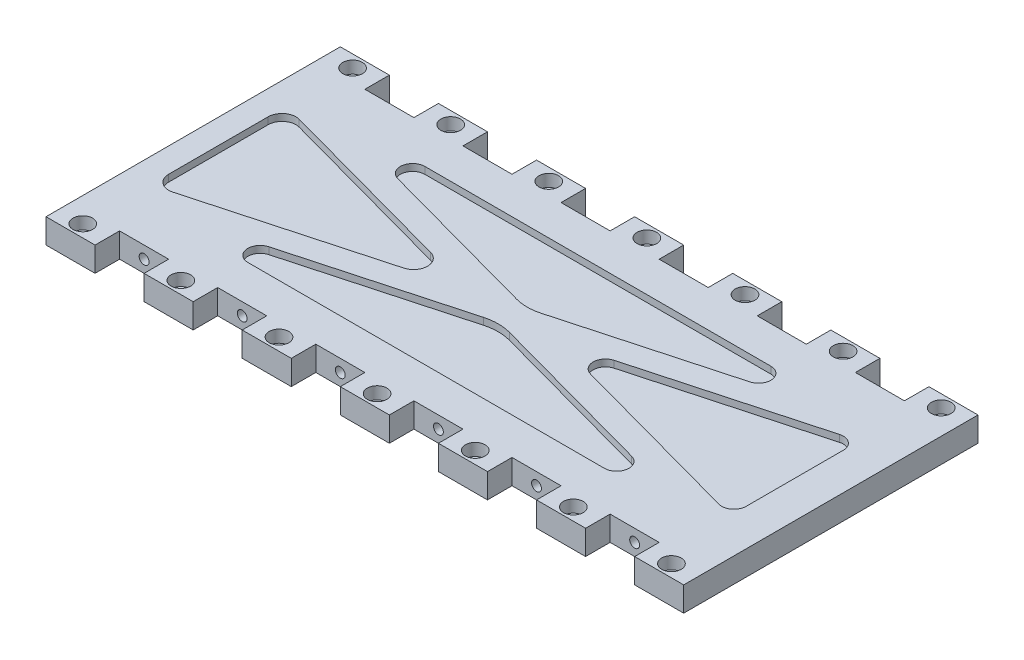
from build123d import *

# Parameters (mm, degrees)
SKETCH1_W           = 330.2
SKETCH1_H           = 127
BOSS_EXTRUDE1_DEPTH = 12.7
CUT_EXTRUDE1_DEPTH  = 3.556
SKETCH3_W           = 25.4
SKETCH3_H           = 12.7
BOSS_EXTRUDE2_DEPTH = 12.7
SKETCH4_R           = 3.2385
CUT_EXTRUDE2_DEPTH  = 25.4
SKETCH5_R           = 5.08
CUT_EXTRUDE3_DEPTH  = 6.35
SKETCH6_R           = 2.5527
CUT_EXTRUDE4_DEPTH  = 25.4


with BuildPart() as part:
    # Sketch1 → Boss-Extrude1 (new body)
    with BuildSketch(Plane(origin=(0, 0, 0), x_dir=(1, 0, 0), z_dir=(0, 1, 0))):
        Rectangle(SKETCH1_W, SKETCH1_H)
    extrude(amount=BOSS_EXTRUDE1_DEPTH)

    # Sketch2 → Cut-Extrude1 (cut)
    with BuildSketch(Plane(origin=(0, 12.7, 0), x_dir=(1, 0, 0), z_dir=(0, 1, 0))):
        with BuildLine():
            Line((-89.555550869, 44.45), (89.555550869, 44.45))
            ThreePointArc((89.555550869, 44.45), (95.848789674, 38.947139505), (91.234685107, 31.976030029))
            Line((91.234685107, 31.976030029), (6.256412404, 8.675797038))
            ThreePointArc((6.256412404, 8.675797038), (0, 7.833614774), (-6.256412404, 8.675797038))
            Line((-6.256412404, 8.675797038), (-91.234685107, 31.976030029))
            ThreePointArc((-91.234685107, 31.976030029), (-95.848789674, 38.947139505), (-89.555550869, 44.45))
        make_face()
        with BuildLine():
            Line((-152.4, 26.105568393), (-152.4, -25.353616872))
            ThreePointArc((-152.4, -25.353616872), (-149.556629033, -31.098337724), (-143.26451887, -32.321418189))
            Line((-143.26451887, -32.321418189), (-49.42612935, -6.591825556))
            ThreePointArc((-49.42612935, -6.591825556), (-44.111657731, 0.375975761), (-49.42612935, 7.343777077))
            Line((-49.42612935, 7.343777077), (-143.26451887, 33.07336971))
            ThreePointArc((-143.26451887, 33.07336971), (-149.556629033, 31.850289245), (-152.4, 26.105568393))
        make_face()
        with BuildLine():
            Line((-92.297993035, -44.45), (92.297993035, -44.45))
            ThreePointArc((92.297993035, -44.45), (98.59123184, -38.947139505), (93.977127273, -31.976030029))
            Line((93.977127273, -31.976030029), (6.716536951, -8.050007285))
            ThreePointArc((6.716536951, -8.050007285), (0, -7.145887171), (-6.716536951, -8.050007285))
            Line((-6.716536951, -8.050007285), (-93.977127273, -31.976030029))
            ThreePointArc((-93.977127273, -31.976030029), (-98.59123184, -38.947139505), (-92.297993035, -44.45))
        make_face()
        with BuildLine():
            Line((146.05, 25.51164), (146.05, -24.759688479))
            ThreePointArc((146.05, -24.759688479), (143.550973746, -29.808698402), (138.020865762, -30.88365845))
            Line((138.020865762, -30.88365845), (46.348592305, -5.747994211))
            ThreePointArc((46.348592305, -5.747994211), (41.677726543, 0.375975761), (46.348592305, 6.499945732))
            Line((46.348592305, 6.499945732), (138.020865762, 31.635609971))
            ThreePointArc((138.020865762, 31.635609971), (143.550973746, 30.560649923), (146.05, 25.51164))
        make_face()
    cut_extrude1 = extrude(amount=-CUT_EXTRUDE1_DEPTH, mode=Mode.SUBTRACT)

    # Sketch3 → Boss-Extrude2 (add)
    with BuildSketch(Plane.XZ):
        with Locations((-101.6, 69.85)):
            Rectangle(SKETCH3_W, SKETCH3_H)
        with Locations((-152.4, 69.85)):
            Rectangle(SKETCH3_W, SKETCH3_H)
        with Locations((-50.8, 69.85)):
            Rectangle(SKETCH3_W, SKETCH3_H)
        with Locations((0, 69.85)):
            Rectangle(SKETCH3_W, SKETCH3_H)
        with Locations((50.8, 69.85)):
            Rectangle(SKETCH3_W, SKETCH3_H)
        with Locations((101.6, 69.85)):
            Rectangle(SKETCH3_W, SKETCH3_H)
        with Locations((152.4, 69.85)):
            Rectangle(SKETCH3_W, SKETCH3_H)
        with Locations((-101.6, -69.85)):
            Rectangle(SKETCH3_W, SKETCH3_H)
        with Locations((-50.8, -69.85)):
            Rectangle(SKETCH3_W, SKETCH3_H)
        with Locations((0, -69.85)):
            Rectangle(SKETCH3_W, SKETCH3_H)
        with Locations((50.8, -69.85)):
            Rectangle(SKETCH3_W, SKETCH3_H)
        with Locations((101.6, -69.85)):
            Rectangle(SKETCH3_W, SKETCH3_H)
        with Locations((152.4, -69.85)):
            Rectangle(SKETCH3_W, SKETCH3_H)
        with Locations((-152.4, -69.85)):
            Rectangle(SKETCH3_W, SKETCH3_H)
    extrude(amount=-BOSS_EXTRUDE2_DEPTH)

    # Sketch4 → Cut-Extrude2 (cut)
    with BuildSketch(Plane(origin=(0, 12.7, 0), x_dir=(1, 0, 0), z_dir=(0, 1, 0))):
        with Locations((-152.4, 69.85)):
            Circle(SKETCH4_R)
        with Locations((-101.6, 69.85)):
            Circle(SKETCH4_R)
        with Locations((-50.8, 69.85)):
            Circle(SKETCH4_R)
        with Locations((0, 69.85)):
            Circle(SKETCH4_R)
        with Locations((50.8, 69.85)):
            Circle(SKETCH4_R)
        with Locations((101.6, 69.85)):
            Circle(SKETCH4_R)
        with Locations((152.4, 69.85)):
            Circle(SKETCH4_R)
        with Locations((-101.6, -69.85)):
            Circle(SKETCH4_R)
        with Locations((-50.8, -69.85)):
            Circle(SKETCH4_R)
        with Locations((0, -69.85)):
            Circle(SKETCH4_R)
        with Locations((50.8, -69.85)):
            Circle(SKETCH4_R)
        with Locations((101.6, -69.85)):
            Circle(SKETCH4_R)
        with Locations((152.4, -69.85)):
            Circle(SKETCH4_R)
        with Locations((-152.4, -69.85)):
            Circle(SKETCH4_R)
    extrude(amount=-CUT_EXTRUDE2_DEPTH, mode=Mode.SUBTRACT)

    # Sketch5 → Cut-Extrude3 (cut)
    with BuildSketch(Plane(origin=(0, 12.7, 0), x_dir=(1, 0, 0), z_dir=(0, 1, 0))):
        with Locations((-152.4, 69.85)):
            Circle(SKETCH5_R)
        with Locations((-101.6, 69.85)):
            Circle(SKETCH5_R)
        with Locations((-50.8, 69.85)):
            Circle(SKETCH5_R)
        with Locations((0, 69.85)):
            Circle(SKETCH5_R)
        with Locations((50.8, 69.85)):
            Circle(SKETCH5_R)
        with Locations((101.6, 69.85)):
            Circle(SKETCH5_R)
        with Locations((152.4, 69.85)):
            Circle(SKETCH5_R)
        with Locations((-101.6, -69.85)):
            Circle(SKETCH5_R)
        with Locations((-50.8, -69.85)):
            Circle(SKETCH5_R)
        with Locations((0, -69.85)):
            Circle(SKETCH5_R)
        with Locations((50.8, -69.85)):
            Circle(SKETCH5_R)
        with Locations((101.6, -69.85)):
            Circle(SKETCH5_R)
        with Locations((152.4, -69.85)):
            Circle(SKETCH5_R)
        with Locations((-152.4, -69.85)):
            Circle(SKETCH5_R)
    extrude(amount=-CUT_EXTRUDE3_DEPTH, mode=Mode.SUBTRACT)

    # Sketch6 → Cut-Extrude4 (cut)
    with BuildSketch(Plane.XY.offset(63.5)):
        with Locations((-127, 6.35)):
            Circle(SKETCH6_R)
        with Locations((-76.2, 6.35)):
            Circle(SKETCH6_R)
        with Locations((-25.4, 6.35)):
            Circle(SKETCH6_R)
        with Locations((25.4, 6.35)):
            Circle(SKETCH6_R)
        with Locations((76.2, 6.35)):
            Circle(SKETCH6_R)
        with Locations((127, 6.35)):
            Circle(SKETCH6_R)
    cut_extrude4 = extrude(amount=-CUT_EXTRUDE4_DEPTH, mode=Mode.SUBTRACT)

    # Mirror1: Cut-Extrude4 across plane
    add(cut_extrude4.mirror(Plane(origin=(0, 0, 0), x_dir=(1, 0, 0), z_dir=(0, 0, -1))), mode=Mode.SUBTRACT)

    # Mirror2: Cut-Extrude1 across plane
    add(cut_extrude1.mirror(Plane.ZX.offset(6.35)), mode=Mode.SUBTRACT)


solid = part.part
